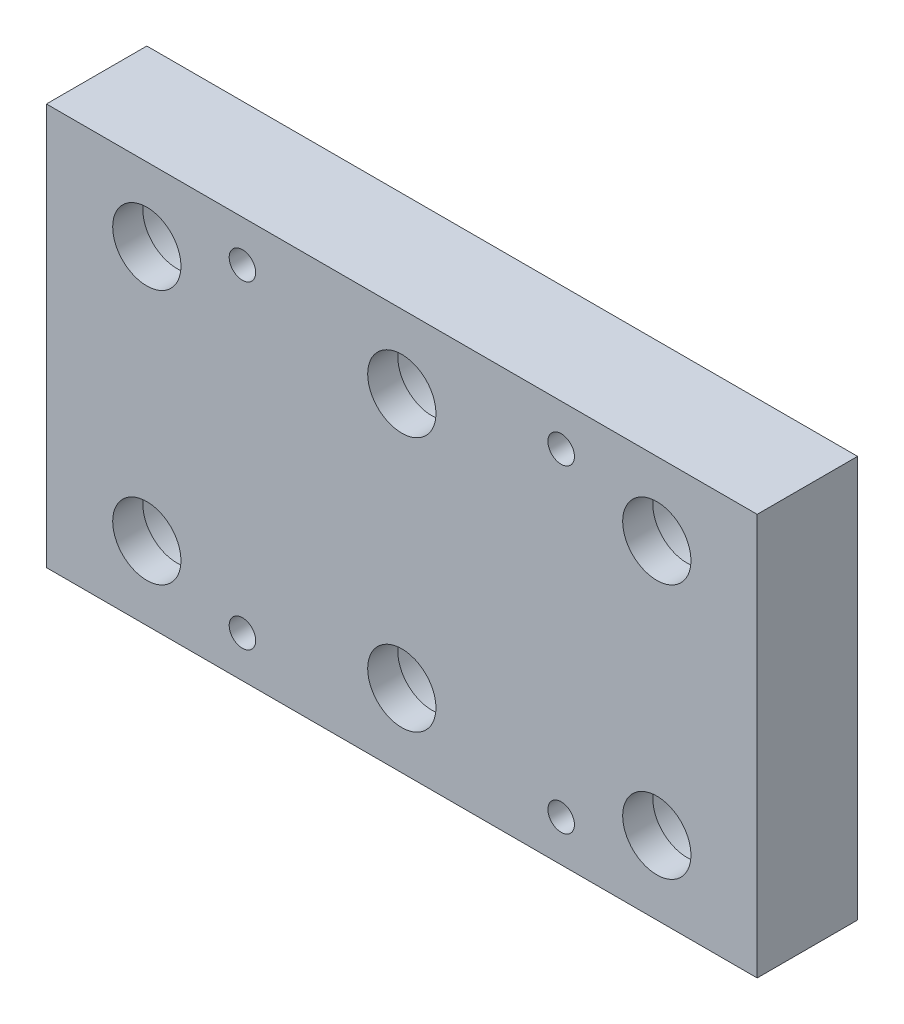
from build123d import *

# Parameters (mm, degrees)
SKETCH1_W           = 70.8
SKETCH1_H           = 40
BOSS_EXTRUDE1_DEPTH = 10
SKETCH2_R           = 1.32
CUT_EXTRUDE1_DEPTH  = 11
SKETCH3_R           = 3.4
CUT_EXTRUDE2_DEPTH  = 11
SKETCH4_R           = 5.375
CUT_EXTRUDE3_DEPTH  = 7


with BuildPart() as part:
    # Sketch1 → Boss-Extrude1 (new body)
    with BuildSketch(Plane.XY):
        Rectangle(SKETCH1_W, SKETCH1_H)
    extrude(amount=BOSS_EXTRUDE1_DEPTH)

    # Sketch2 → Cut-Extrude1 (cut, through all)
    with BuildSketch(Plane.XY.offset(10)):
        with Locations((15.875, -15.875)):
            Circle(SKETCH2_R)
        with Locations((-15.875, -15.875)):
            Circle(SKETCH2_R)
        with Locations((-15.875, 15.875)):
            Circle(SKETCH2_R)
        with Locations((15.875, 15.875)):
            Circle(SKETCH2_R)
    extrude(amount=-CUT_EXTRUDE1_DEPTH, mode=Mode.SUBTRACT)

    # Sketch3 → Cut-Extrude2 (cut, through all)
    with BuildSketch(Plane(origin=(0, 0, 0), x_dir=(-1, 0, 0), z_dir=(0, 0, -1))):
        with Locations((-25.4, -12.7)):
            Circle(SKETCH3_R)
        with Locations((0, -12.7)):
            Circle(SKETCH3_R)
        with Locations((25.4, -12.7)):
            Circle(SKETCH3_R)
        with Locations((0, 12.7)):
            Circle(SKETCH3_R)
        with Locations((25.4, 12.7)):
            Circle(SKETCH3_R)
        with Locations((-25.4, 12.7)):
            Circle(SKETCH3_R)
    extrude(amount=-CUT_EXTRUDE2_DEPTH, mode=Mode.SUBTRACT)

    # Sketch4 → Cut-Extrude3 (cut)
    with BuildSketch(Plane(origin=(0, 0, 0), x_dir=(-1, 0, 0), z_dir=(0, 0, -1))):
        with Locations((25.4, -12.7)):
            Circle(SKETCH4_R)
        with Locations((0, -12.7)):
            Circle(SKETCH4_R)
        with Locations((-25.4, -12.7)):
            Circle(SKETCH4_R)
        with Locations((0, 12.7)):
            Circle(SKETCH4_R)
        with Locations((-25.4, 12.7)):
            Circle(SKETCH4_R)
        with Locations((25.4, 12.7)):
            Circle(SKETCH4_R)
    extrude(amount=-CUT_EXTRUDE3_DEPTH, mode=Mode.SUBTRACT)


solid = part.part
